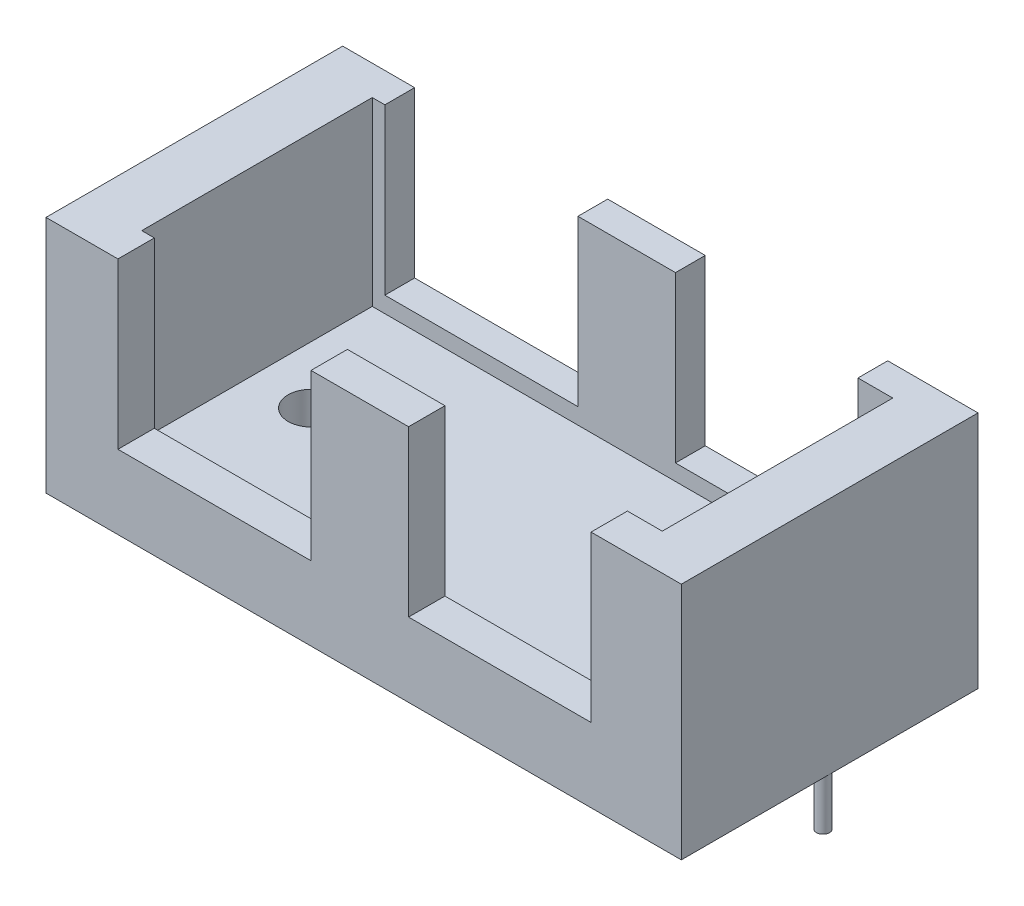
from build123d import *

# Parameters (mm, degrees)
SKETCH1_W           = 43.9
SKETCH1_H           = 20.5
BOSS_EXTRUDE1_DEPTH = 16.5
SKETCH3_R           = 1.6
CUT_EXTRUDE1_DEPTH  = 6.5
SKETCH5_W           = 35.96646031
SKETCH5_H           = 15.929900813
CUT_EXTRUDE3_DEPTH  = 12.5
SKETCH4_W           = 12.608694843
SKETCH4_H           = 15.64948953
SKETCH4_W_2         = 13.340907584
CUT_EXTRUDE4_DEPTH  = 28.5
SKETCH6_R           = 0.45
BOSS_EXTRUDE2_DEPTH = 3.5


with BuildPart() as part:
    # Sketch1 → Boss-Extrude1 (new body)
    with BuildSketch(Plane(origin=(0, 0, 0), x_dir=(1, 0, 0), z_dir=(0, 1, 0))):
        with Locations((-0.724764151, -1.035141509)):
            Rectangle(SKETCH1_W, SKETCH1_H)
    extrude(amount=BOSS_EXTRUDE1_DEPTH)

    # Sketch3 → Cut-Extrude1 (cut)
    with BuildSketch(Plane(origin=(0, 0, 0), x_dir=(-1, 0, 0), z_dir=(0, -1, 0))):
        with Locations((-13.145235849, -1.035141509)):
            Circle(SKETCH3_R)
        with Locations((14.594764151, -1.035141509)):
            Circle(SKETCH3_R)
    extrude(amount=-CUT_EXTRUDE1_DEPTH, mode=Mode.SUBTRACT)

    # Sketch5 → Cut-Extrude3 (cut)
    with BuildSketch(Plane(origin=(0, 16.5, 0), x_dir=(1, 0, 0), z_dir=(0, 1, 0))):
        with Locations((-0.591045911, -0.805962597)):
            Rectangle(SKETCH5_W, SKETCH5_H)
    extrude(amount=-CUT_EXTRUDE3_DEPTH, mode=Mode.SUBTRACT)

    # Sketch4 → Cut-Extrude4 (cut)
    with BuildSketch(Plane(origin=(0, 0, -9.214858491), x_dir=(-1, 0, 0), z_dir=(0, 0, -1))):
        with Locations((-8.682774774, 12.932468191)):
            Rectangle(SKETCH4_W, SKETCH4_H)
        with Locations((11.03272818, 12.932468191)):
            Rectangle(SKETCH4_W_2, SKETCH4_H)
    extrude(amount=-CUT_EXTRUDE4_DEPTH, mode=Mode.SUBTRACT)

    # Sketch6 → Boss-Extrude2 (add)
    with BuildSketch(Plane.XZ):
        with Locations((20.765235849, 1.035141509)):
            Circle(SKETCH6_R)
        with Locations((-22.214764151, 1.035141509)):
            Circle(SKETCH6_R)
    extrude(amount=BOSS_EXTRUDE2_DEPTH)


solid = part.part
